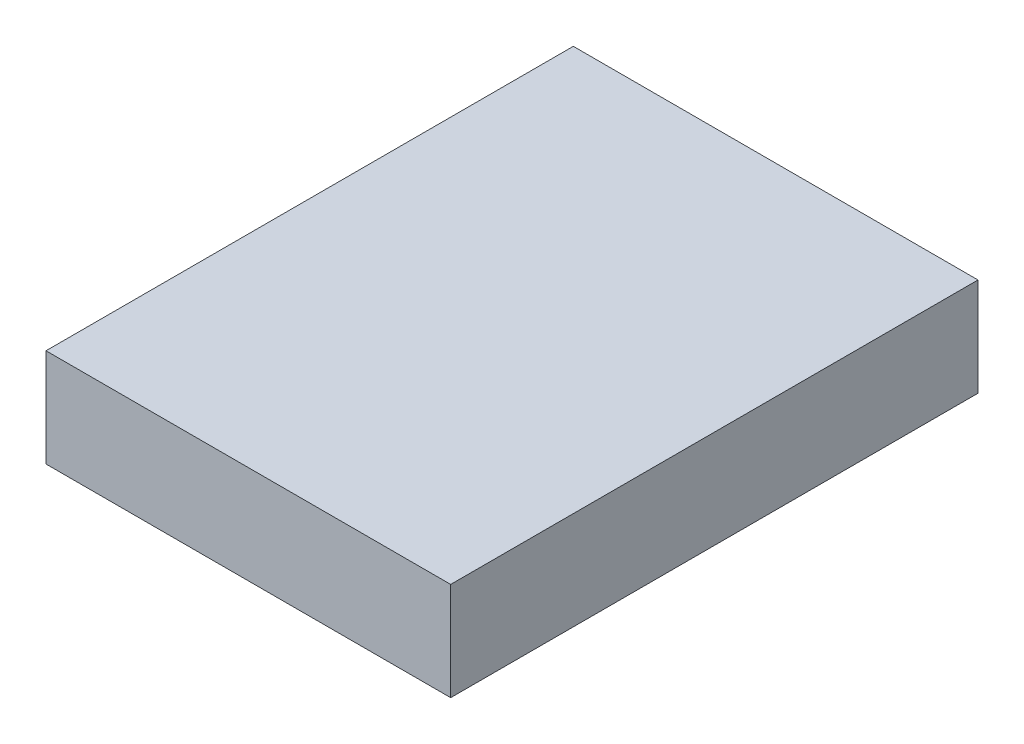
from build123d import *

# Parameters (mm, degrees)
SKETCH2_W           = 52.3875
SKETCH2_H           = 68.2625
BOSS_EXTRUDE1_DEPTH = 12.7


with BuildPart() as part:
    # Sketch2 → Boss-Extrude1 (new body)
    with BuildSketch(Plane(origin=(0, 0, 0), x_dir=(1, 0, 0), z_dir=(0, 1, 0))):
        with Locations((26.19375, 34.13125)):
            Rectangle(SKETCH2_W, SKETCH2_H)
    extrude(amount=BOSS_EXTRUDE1_DEPTH)


solid = part.part
